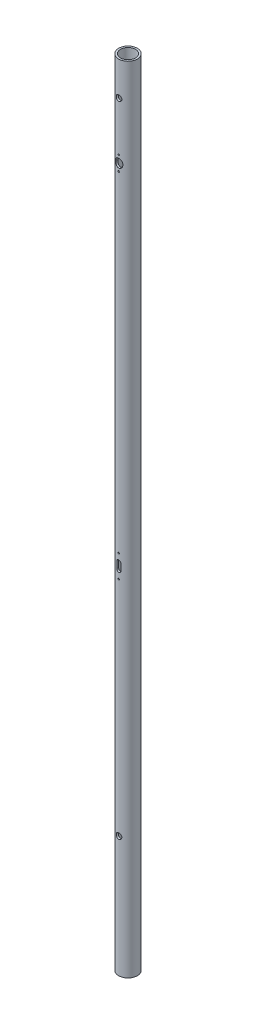
from build123d import *

# Parameters (mm, degrees)
SKETCH1_R           = 21.082
SKETCH1_R_2         = 16.891
BOSS_EXTRUDE1_DEPTH = 1790.7
SKETCH2_R           = 6.35
CUT_EXTRUDE1_DEPTH  = 21.082
SKETCH3_R           = 1.651
CUT_EXTRUDE2_DEPTH  = 21.082
CUT_EXTRUDE3_DEPTH  = 21.082


with BuildPart() as part:
    # Sketch1 → Boss-Extrude1 (new body)
    with BuildSketch(Plane(origin=(0, 0, 0), x_dir=(1, 0, 0), z_dir=(0, 1, 0))):
        Circle(SKETCH1_R)
        Circle(SKETCH1_R_2, mode=Mode.SUBTRACT)
    extrude(amount=BOSS_EXTRUDE1_DEPTH)

    # Sketch2 → Cut-Extrude1 (cut, symmetric)
    with BuildSketch(Plane.XY):
        with Locations((0, 1714.5)):
            Circle(SKETCH2_R)
        with Locations((0, 273.05)):
            Circle(SKETCH2_R)
    extrude(amount=CUT_EXTRUDE1_DEPTH, both=True, mode=Mode.SUBTRACT)

    # Sketch3 → Cut-Extrude2 (cut, symmetric)
    with BuildSketch(Plane.XY):
        with Locations((0, 1603.756)):
            Circle(SKETCH3_R)
        with Locations((0, 1570.99)):
            Circle(SKETCH3_R)
        with Locations((0, 774.7)):
            Circle(SKETCH3_R)
        with Locations((0, 825.5)):
            Circle(SKETCH3_R)
    extrude(amount=CUT_EXTRUDE2_DEPTH, both=True, mode=Mode.SUBTRACT)

    # Sketch5 → Cut-Extrude3 (cut, symmetric)
    with BuildSketch(Plane.XY):
        with BuildLine():
            Line((7.874, 1589.024), (7.874, 1585.722))
            ThreePointArc((7.874, 1585.722), (0, 1577.848), (-7.874, 1585.722))
            Line((-7.874, 1585.722), (-7.874, 1589.024))
            ThreePointArc((-7.874, 1589.024), (0, 1596.898), (7.874, 1589.024))
        make_face()
        with BuildLine():
            Line((4.826, 807.466), (4.826, 792.734))
            ThreePointArc((4.826, 792.734), (0, 787.908), (-4.826, 792.734))
            Line((-4.826, 792.734), (-4.826, 807.466))
            ThreePointArc((-4.826, 807.466), (0, 812.292), (4.826, 807.466))
        make_face()
    extrude(amount=CUT_EXTRUDE3_DEPTH, both=True, mode=Mode.SUBTRACT)


solid = part.part
